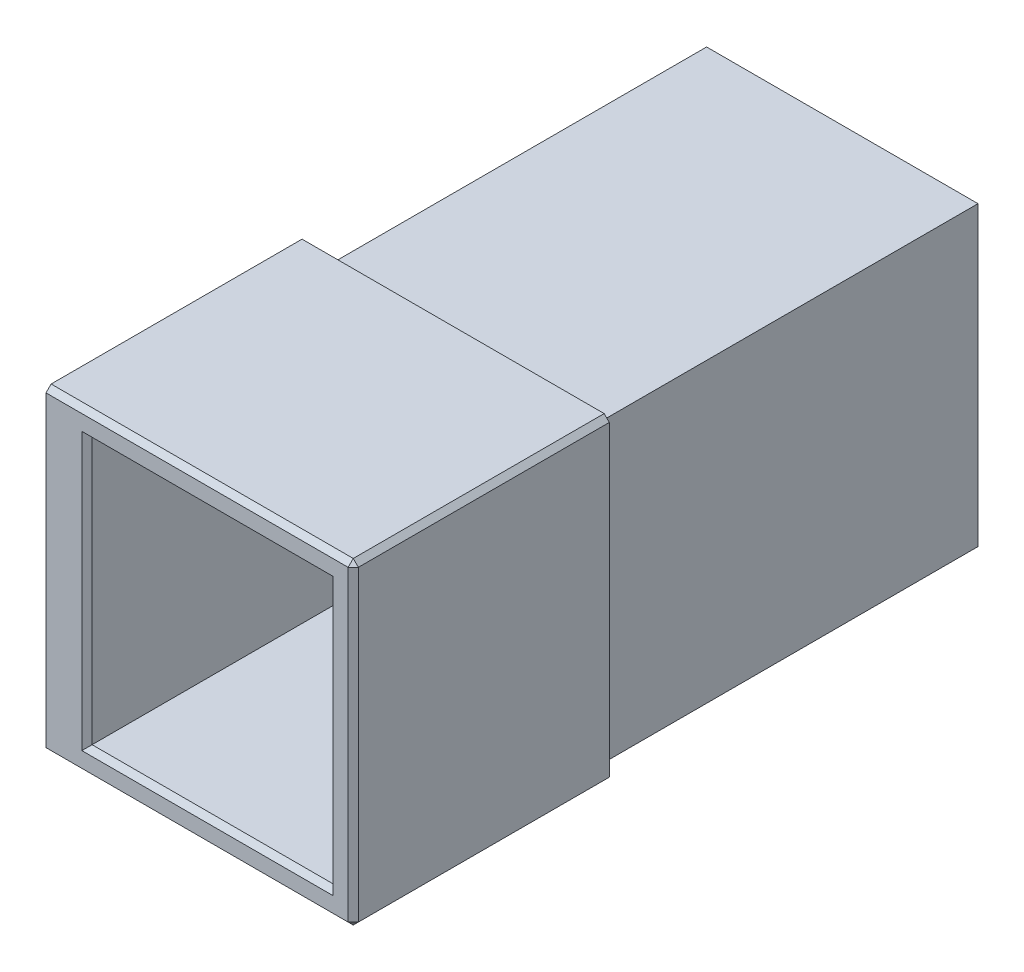
from build123d import *

# Parameters (mm, degrees)
SKETCH1_W           = 47
SKETCH1_H           = 52
BOSS_EXTRUDE1_DEPTH = 50
SKETCH8_W           = 25
SKETCH8_H           = 16
CUT_EXTRUDE1_DEPTH  = 10
CUT_EXTRUDE2_START  = -2
CUT_EXTRUDE2_DEPTH  = 3.5
CUT_EXTRUDE3_DEPTH  = 3.5
CHAMFER1_SIZE       = 1
SKETCH6_W           = 53
SKETCH6_H           = 58
SKETCH6_W_2         = 47
SKETCH6_H_2         = 52
BOSS_EXTRUDE3_DEPTH = 74
CHAMFER2_SIZE       = 1


with BuildPart() as part:
    # Sketch1 → Boss-Extrude1 (new body)
    with BuildSketch(Plane.XY):
        Polygon((17.540775456, -97.544656267), (17.540775456, -113.544656267), (9.540775456, -113.544656267), (9.540775456, -35.544656267), (69.540775456, -35.544656267), (69.540775456, -97.544656267), align=None)
        with Locations((41.040775456, -66.544656267)):
            Rectangle(SKETCH1_W, SKETCH1_H, mode=Mode.SUBTRACT)
    extrude(amount=BOSS_EXTRUDE1_DEPTH)

    # Sketch8 → Cut-Extrude1 (cut)
    with BuildSketch(Plane(origin=(17.540775456, 0, 0), x_dir=(0, 0, -1), z_dir=(1, 0, 0))):
        with Locations((-37.5, -105.544656267)):
            Rectangle(SKETCH8_W, SKETCH8_H)
    extrude(amount=-CUT_EXTRUDE1_DEPTH, mode=Mode.SUBTRACT)

    # Sketch9 → Cut-Extrude2 (cut)
    with BuildSketch(Plane.ZY.offset(-9.540775456).offset(CUT_EXTRUDE2_START)):
        with BuildLine():
            Line((35, -49.794656267), (28, -49.794656267))
            ThreePointArc((28, -49.794656267), (24.25, -46.044656267), (28, -42.294656267))
            Line((28, -42.294656267), (35, -42.294656267))
            ThreePointArc((35, -42.294656267), (38.75, -46.044656267), (35, -49.794656267))
        make_face()
        with BuildLine():
            Line((15, -106.794656267), (8, -106.794656267))
            ThreePointArc((8, -106.794656267), (4.25, -103.044656267), (8, -99.294656267))
            Line((8, -99.294656267), (15, -99.294656267))
            ThreePointArc((15, -99.294656267), (18.75, -103.044656267), (15, -106.794656267))
        make_face()
    extrude(amount=-CUT_EXTRUDE2_DEPTH, mode=Mode.SUBTRACT)

    # Sketch10 → Cut-Extrude3 (cut)
    with BuildSketch(Plane.ZY.offset(-9.540775456)):
        with BuildLine():
            Line((35, -48.094656267), (32.478839135, -48.094656267))
            ThreePointArc((32.478839135, -48.094656267), (31.41425784, -48.289898404), (30.488243964, -48.850211822))
            ThreePointArc((30.488243964, -48.850211822), (24.25, -46.044656267), (30.488243964, -43.239100711))
            ThreePointArc((30.488243964, -43.239100711), (31.41425784, -43.799414129), (32.478839135, -43.994656267))
            Line((32.478839135, -43.994656267), (35, -43.994656267))
            ThreePointArc((35, -43.994656267), (37.05, -46.044656267), (35, -48.094656267))
        make_face()
        with BuildLine():
            Line((12.478839135, -100.994656267), (15, -100.994656267))
            ThreePointArc((15, -100.994656267), (17.05, -103.044656267), (15, -105.094656267))
            Line((15, -105.094656267), (12.478839135, -105.094656267))
            ThreePointArc((12.478839135, -105.094656267), (11.41425784, -105.289898404), (10.488243964, -105.850211822))
            ThreePointArc((10.488243964, -105.850211822), (4.25, -103.044656267), (10.488243964, -100.239100711))
            ThreePointArc((10.488243964, -100.239100711), (11.41425784, -100.799414129), (12.478839135, -100.994656267))
        make_face()
    extrude(amount=-CUT_EXTRUDE3_DEPTH, mode=Mode.SUBTRACT)

    # Chamfer1
    chamfer1_edges = [part.edges().sort_by_distance(p)[0] for p in [
        (69.540775456, -35.544656267, 25),
        (69.540775456, -97.544656267, 25),
        (39.540775456, -35.544656267, 50),
        (17.540775456, -66.544656267, 50),
        (41.040775456, -92.544656267, 50),
        (64.540775456, -66.544656267, 50),
        (41.040775456, -40.544656267, 50),
        (17.540775456, -97.544656267, 12.5),
        (17.540775456, -113.544656267, 12.5),
        (13.540775456, -97.544656267, 25),
        (17.540775456, -105.544656267, 25),
        (39.540775456, -97.544656267, 50),
        (69.540775456, -66.544656267, 50),
    ]]
    chamfer(chamfer1_edges, length=CHAMFER1_SIZE)

    # Sketch6 → Boss-Extrude3 (add)
    with BuildSketch(Plane(origin=(0, 0, 0), x_dir=(-1, 0, 0), z_dir=(0, 0, -1))):
        with Locations((-41.040775456, -66.544656267)):
            Rectangle(SKETCH6_W, SKETCH6_H)
        with Locations((-41.040775456, -66.544656267)):
            Rectangle(SKETCH6_W_2, SKETCH6_H_2, mode=Mode.SUBTRACT)
    extrude(amount=BOSS_EXTRUDE3_DEPTH)

    # Chamfer2
    chamfer2_edges = [part.edges().sort_by_distance(p)[0] for p in [
        (67.540775456, -66.544656267, 0),
        (41.040775456, -95.544656267, 0),
        (14.540775456, -66.544656267, 0),
        (41.040775456, -37.544656267, 0),
    ]]
    chamfer(chamfer2_edges, length=CHAMFER2_SIZE)


solid = part.part
